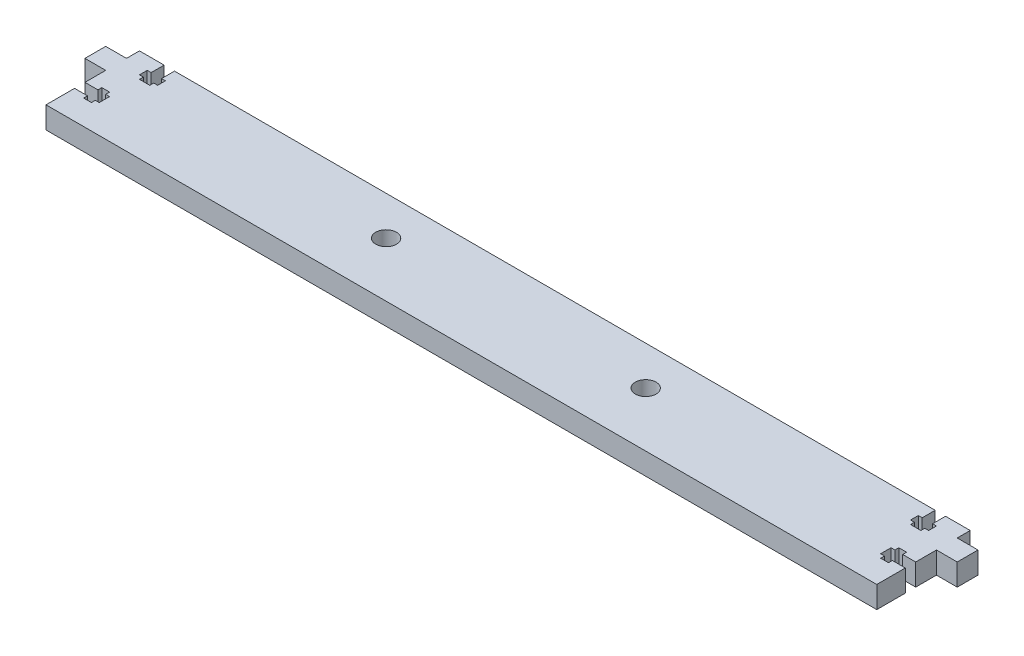
from build123d import *

# Parameters (mm, degrees)
SKETCH1_R           = 4
BOSS_EXTRUDE1_DEPTH = 8.4


with BuildPart() as part:
    # Sketch1 → Boss-Extrude1 (new body)
    with BuildSketch(Plane(origin=(0, 0, 0), x_dir=(1, 0, 0), z_dir=(0, 1, 0))):
        Polygon((-160, 18), (-150.5, 18), (-150.5, 13), (-152, 13), (-152, 10), (-150.5, 10), (-150.5, 8.5), (-146.5, 8.5), (-146.5, 10), (-145, 10), (-145, 13), (-146.5, 13), (-146.5, 18), (146.5, 18), (146.5, 13), (145, 13), (145, 10), (146.5, 10), (146.5, 8.5), (150.5, 8.5), (150.5, 10), (152, 10), (152, 13), (150.5, 13), (150.5, 18), (160, 18), (160, 13), (168, 13), (168, 5), (160, 5), (160, -3), (155, -3), (155, -1.5), (152, -1.5), (152, -3), (150.5, -3), (150.5, -7), (152, -7), (152, -8.5), (155, -8.5), (155, -7), (160, -7), (160, -18), (-160, -18), (-160, -7), (-155, -7), (-155, -8.5), (-152, -8.5), (-152, -7), (-150.5, -7), (-150.5, -3), (-152, -3), (-152, -1.5), (-155, -1.5), (-155, -3), (-160, -3), (-160, 5), (-168, 5), (-168, 13), (-160, 13), align=None)
        with Locations((-50, 3)):
            Circle(SKETCH1_R, mode=Mode.SUBTRACT)
        with Locations((50, 3)):
            Circle(SKETCH1_R, mode=Mode.SUBTRACT)
    extrude(amount=BOSS_EXTRUDE1_DEPTH)


solid = part.part
